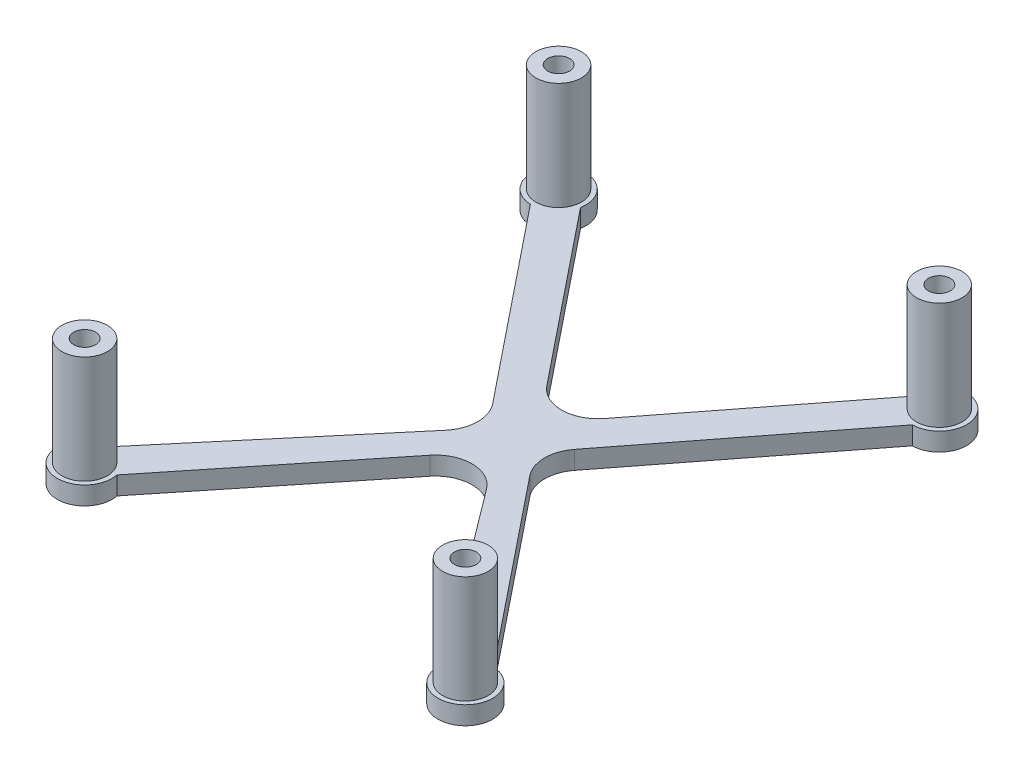
from build123d import *

# Parameters (mm, degrees)
BOSS_EXTRUDE1_DEPTH                                 = 2.54
SKETCH2_R                                           = 3.175
BOSS_EXTRUDE2_DEPTH                                 = 15
CBORE_FOR_00_BINDING_HEAD_MACHINE_SCREW_D           = 3.048
CBORE_FOR_00_BINDING_HEAD_MACHINE_SCREW_CBORE_D     = 5.715
CBORE_FOR_00_BINDING_HEAD_MACHINE_SCREW_CBORE_DEPTH = 5.08
CBORE_FOR_00_BINDING_HEAD_MACHINE_S_2_D             = 3.048
CBORE_FOR_00_BINDING_HEAD_MACHINE_S_2_CBORE_D       = 5.715
CBORE_FOR_00_BINDING_HEAD_MACHINE_S_2_CBORE_DEPTH   = 5.08


with BuildPart() as part:
    # Sketch1 → Boss-Extrude1 (new body)
    with BuildSketch(Plane.XZ.offset(14.999999665)):
        with BuildLine():
            ThreePointArc((-118.732237126, 41.291635073), (-119.799942246, 44.449254661), (-118.68060362, 47.588942022))
            Line((-118.68060362, 47.588942022), (-98.069142774, 73.248424617))
            ThreePointArc((-98.069142774, 73.248424617), (-95.812668617, 80.026590118), (-101.944824249, 76.361638481))
            Line((-101.944824249, 76.361638481), (-120.087244283, 52.215986296))
            ThreePointArc((-120.087244283, 52.215986296), (-124.066396106, 50.188221558), (-128.109054429, 52.086218591))
            Line((-128.109054429, 52.086218591), (-147.547470085, 76.285361579))
            ThreePointArc((-147.547470085, 76.285361579), (-153.664676639, 80.026590118), (-151.33049651, 73.246574622))
            Line((-151.33049651, 73.246574622), (-130.017313744, 47.964682708))
            ThreePointArc((-130.017313744, 47.964682708), (-128.821664975, 44.750582309), (-129.940817748, 41.509052665))
            Line((-129.940817748, 41.509052665), (-151.408202483, 14.784019002))
            ThreePointArc((-151.408202483, 14.784019002), (-153.664676639, 8.0058535), (-147.532521008, 11.670805138))
            Line((-147.532521008, 11.670805138), (-128.34443149, 35.558313777))
            ThreePointArc((-128.34443149, 35.558313777), (-124.342289826, 37.456804622), (-120.37181674, 35.49294392))
            Line((-120.37181674, 35.49294392), (-101.929875172, 11.74708204))
            ThreePointArc((-101.929875172, 11.74708204), (-95.812668617, 8.0058535), (-98.146848747, 14.785868997))
            Line((-98.146848747, 14.785868997), (-118.732237126, 41.291635073))
        make_face()
    extrude(amount=BOSS_EXTRUDE1_DEPTH)

    # Sketch2 → Boss-Extrude2 (add)
    with BuildSketch(Plane(origin=(0, -14.999999665, 0), x_dir=(1, 0, 0), z_dir=(0, 1, 0))):
        with Locations((-98.19867242, -10.976221467)):
            Circle(SKETCH2_R)
        with Locations((-151.278672837, -10.976221467)):
            Circle(SKETCH2_R)
        with Locations((-151.278672837, -77.056222152)):
            Circle(SKETCH2_R)
        with Locations((-98.19867242, -77.056222152)):
            Circle(SKETCH2_R)
    extrude(amount=BOSS_EXTRUDE2_DEPTH)

    # CBORE for _00 Binding Head Machine Screw (through all)
    with Locations(Plane(origin=(0, -17.539999665, 0), x_dir=(-1, 0, 0), z_dir=(0, -1, 0))):
        with Locations((151.278672837, -10.976221467)):
            CounterBoreHole(CBORE_FOR_00_BINDING_HEAD_MACHINE_SCREW_D / 2, CBORE_FOR_00_BINDING_HEAD_MACHINE_SCREW_CBORE_D / 2, CBORE_FOR_00_BINDING_HEAD_MACHINE_SCREW_CBORE_DEPTH)

    # CBORE for _00 Binding Head Machine S 2 (through all)
    with Locations(Plane(origin=(0, -17.539999665, 0), x_dir=(-1, 0, 0), z_dir=(0, -1, 0))):
        with Locations((98.19867242, -10.976221467), (98.19867242, -77.056222152), (151.278672837, -77.056222152)):
            CounterBoreHole(CBORE_FOR_00_BINDING_HEAD_MACHINE_S_2_D / 2, CBORE_FOR_00_BINDING_HEAD_MACHINE_S_2_CBORE_D / 2, CBORE_FOR_00_BINDING_HEAD_MACHINE_S_2_CBORE_DEPTH)


solid = part.part
